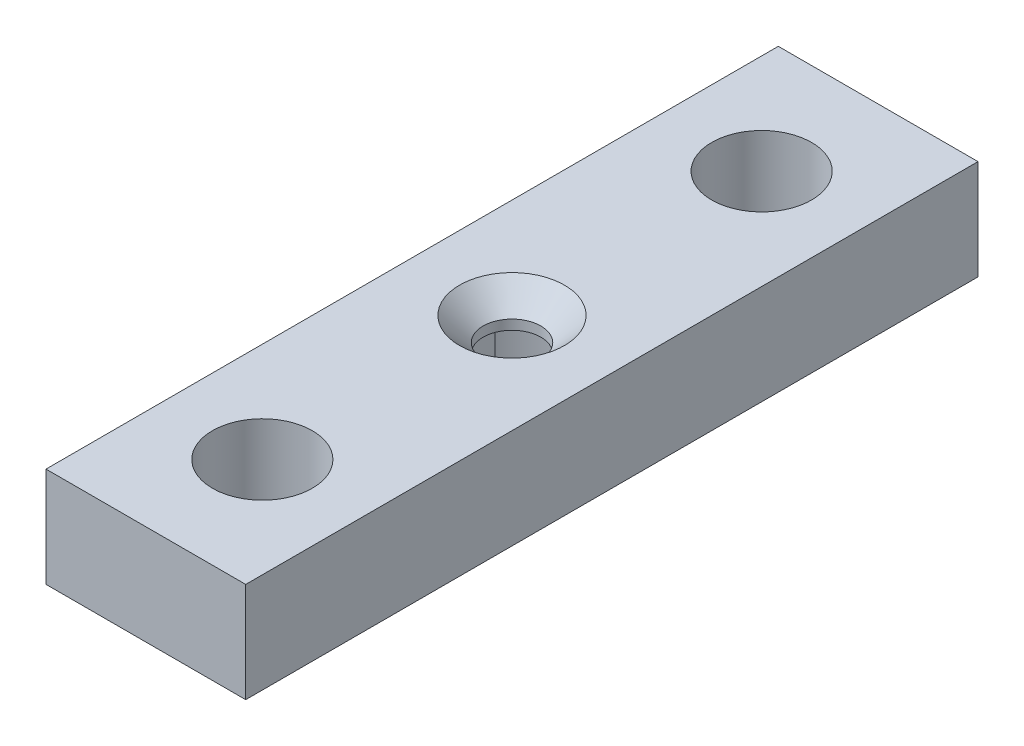
from build123d import *

# Parameters (mm, degrees)
SKETCH1_W                                        = 38.1
SKETCH1_H                                        = 19.05
EXTRUDE1_DEPTH                                   = 69.85
CUT_EXTRUDE1_REACH                               = 21.05
SKETCH2_R                                        = 9.525
CSK_FOR_M10_FLAT_HEAD_MACHINE_SCREW1_D           = 11
CSK_FOR_M10_FLAT_HEAD_MACHINE_SCREW1_DEPTH       = 29.464
CSK_FOR_M10_FLAT_HEAD_MACHINE_SCREW1_CSINK_D     = 20
CSK_FOR_M10_FLAT_HEAD_MACHINE_SCREW1_CSINK_ANGLE = 90
CSK_FOR_M10_FLAT_HEAD_MACHINE_SCREW1_TIP         = 3.304733405
SKETCH5_R                                        = 15.9385
CUT_EXTRUDE2_DEPTH                               = 12.7
BOSS_EXTRUDE1_DEPTH                              = 12.7


with BuildPart() as part:
    # Sketch1 → Extrude1 (new body, symmetric)
    with BuildSketch(Plane.XY):
        Rectangle(SKETCH1_W, SKETCH1_H)
    extrude(amount=EXTRUDE1_DEPTH, both=True)

    # Sketch2 → Cut-Extrude1 (cut, up to next)
    with BuildSketch(Plane(origin=(0, 9.525, 0), x_dir=(1, 0, 0), z_dir=(0, 1, 0)), mode=Mode.PRIVATE) as cut_extrude1_sk1:
        with Locations((0, 47.625)):
            Circle(SKETCH2_R)
    cut_extrude1_tool1 = extrude(cut_extrude1_sk1.sketch, amount=-CUT_EXTRUDE1_REACH, mode=Mode.PRIVATE) & part.part
    add(cut_extrude1_tool1.solids().sort_by_distance((0, 9.525, -47.625))[0], mode=Mode.SUBTRACT)
    # Sketch2 → Cut-Extrude1 (cut, up to next)
    with BuildSketch(Plane(origin=(0, 9.525, 0), x_dir=(1, 0, 0), z_dir=(0, 1, 0)), mode=Mode.PRIVATE) as cut_extrude1_sk2:
        with Locations((0, -47.625)):
            Circle(SKETCH2_R)
    cut_extrude1_tool2 = extrude(cut_extrude1_sk2.sketch, amount=-CUT_EXTRUDE1_REACH, mode=Mode.PRIVATE) & part.part
    add(cut_extrude1_tool2.solids().sort_by_distance((0, 9.525, 47.625))[0], mode=Mode.SUBTRACT)

    # CSK for M10 Flat Head Machine Screw1
    with Locations(Plane(origin=(0, 9.525, 0), x_dir=(-1, 0, 0), z_dir=(0, 1, 0))):
        with Locations((0, 0)):
            CounterSinkHole(CSK_FOR_M10_FLAT_HEAD_MACHINE_SCREW1_D / 2, CSK_FOR_M10_FLAT_HEAD_MACHINE_SCREW1_CSINK_D / 2, depth=CSK_FOR_M10_FLAT_HEAD_MACHINE_SCREW1_DEPTH, counter_sink_angle=CSK_FOR_M10_FLAT_HEAD_MACHINE_SCREW1_CSINK_ANGLE)
            with Locations((0, 0, -(CSK_FOR_M10_FLAT_HEAD_MACHINE_SCREW1_DEPTH + CSK_FOR_M10_FLAT_HEAD_MACHINE_SCREW1_TIP / 2))):  # 118° drill point
                Cone(0, CSK_FOR_M10_FLAT_HEAD_MACHINE_SCREW1_D / 2, CSK_FOR_M10_FLAT_HEAD_MACHINE_SCREW1_TIP, mode=Mode.SUBTRACT)

    # Sketch5 → Cut-Extrude2 (cut)
    with BuildSketch(Plane.XZ.offset(9.525)):
        Circle(SKETCH5_R)
    extrude(amount=-CUT_EXTRUDE2_DEPTH, mode=Mode.SUBTRACT)

    # Sketch6 → Boss-Extrude1 (add)
    with BuildSketch(Plane.XZ.offset(9.525)):
        with BuildLine():
            Line((-12.7635, 9.5461432), (-12.7635, -9.5461432))
            ThreePointArc((-12.7635, -9.5461432), (-15.9385, 0), (-12.7635, 9.5461432))
        make_face()
        with BuildLine():
            Line((12.7635, 9.5461432), (12.7635, -9.5461432))
            ThreePointArc((12.7635, -9.5461432), (15.9385, 0), (12.7635, 9.5461432))
        make_face()
    extrude(amount=-BOSS_EXTRUDE1_DEPTH)


solid = part.part
